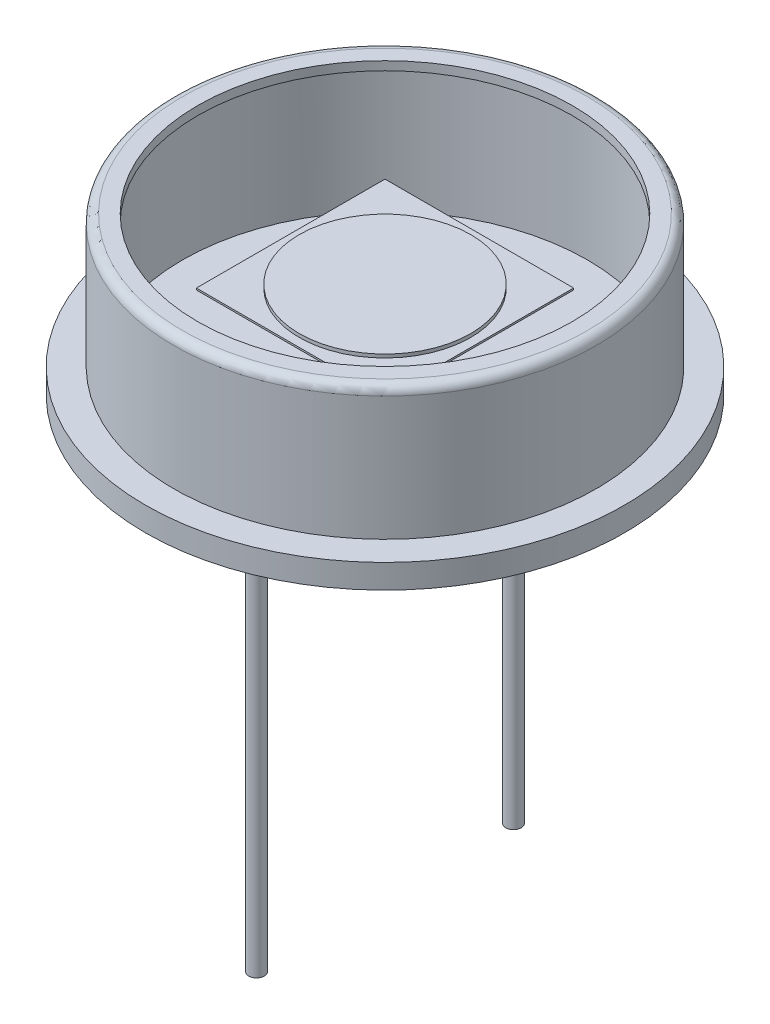
from build123d import *

# Parameters (mm, degrees)
SKETCH2_R           = 6.985
BOSS_EXTRUDE1_DEPTH = 0.446
BOSS_EXTRUDE2_START = -2.69
SKETCH3_W           = 5.5
SKETCH3_H           = 5.5
BOSS_EXTRUDE2_DEPTH = 0.05
SKETCH8_R           = 2.5
BOSS_EXTRUDE6_DEPTH = 0.1
SKETCH5_R           = 0.225
BOSS_EXTRUDE4_DEPTH = 12.7
SKETCH7_R           = 0.75
BOSS_EXTRUDE5_DEPTH = 0.4
SKETCH9_R           = 0.945778117
BOSS_EXTRUDE7_DEPTH = 0.01


with BuildPart() as part:
    # Sketch1 → Revolve-Thin2 (revolve)
    with BuildSketch(Plane.XY, mode=Mode.PRIVATE) as revolve_thin2_sk:
        with BuildLine():
            Line((6.985, 0), (6.985, 0.7))
            Line((6.985, 0.7), (6.16, 0.7))
            Line((6.16, 0.7), (6.16, 4.316))
            ThreePointArc((6.16, 4.316), (6.085605122, 4.495605122), (5.906, 4.57))
            Line((5.906, 4.57), (5.46, 4.57))
            Line((5.46, 4.57), (5.46, 4.316))
            Line((5.46, 4.316), (5.906, 4.316))
            Line((5.906, 4.316), (5.906, 0.446))
            Line((5.906, 0.446), (6.731, 0.446))
            Line((6.731, 0.446), (6.731, 0))
            Line((6.731, 0), (6.985, 0))
        make_face()
    revolve(revolve_thin2_sk.sketch.rotate(Axis((0, 0, 0), (0, 1, 0)), 90), axis=Axis((0, 0, 0), (0, 1, 0)))  # turned: the seam where the file's is

    # Sketch2 → Boss-Extrude1 (add)
    with BuildSketch(Plane.XZ):
        with Locations(Location((0, 0, 0), (0, 0, 270))):  # turned: the seam where the file's is
            Circle(SKETCH2_R)
    extrude(amount=-BOSS_EXTRUDE1_DEPTH)

    # Sketch5 → Boss-Extrude4 (add)
    with BuildSketch(Plane.XZ):
        with Locations(Location((0, -3.745, 0), (0, 0, 90))):  # turned: the seam where the file's is
            Circle(SKETCH5_R)
        with Locations(Location((0, 3.745, 0), (0, 0, 90))):  # turned: the seam where the file's is
            Circle(SKETCH5_R)
    extrude(amount=BOSS_EXTRUDE4_DEPTH)

    # Sketch7 → Boss-Extrude5 (add)
    with BuildSketch(Plane.XZ):
        with Locations(Location((0, 3.745, 0), (0, 0, 90))):  # turned: the seam where the file's is
            Circle(SKETCH7_R)
    extrude(amount=BOSS_EXTRUDE5_DEPTH)

    # Sketch9 → Boss-Extrude7 (add)
    with BuildSketch(Plane.XZ):
        with Locations(Location((-1.979317746, -4.717617413, 0), (0, 0, 90))):  # turned: the seam where the file's is
            Circle(SKETCH9_R)
    extrude(amount=BOSS_EXTRUDE7_DEPTH)


with BuildPart() as body_2:
    # Sketch3 → Boss-Extrude2 (new body)
    with BuildSketch(Plane.XZ.offset(BOSS_EXTRUDE2_START)):
        Rectangle(SKETCH3_W, SKETCH3_H)
    extrude(amount=BOSS_EXTRUDE2_DEPTH)

    # Sketch8 → Boss-Extrude6 (add)
    with BuildSketch(Plane(origin=(0, 2.69, 0), x_dir=(-1, 0, 0), z_dir=(0, 1, 0))):
        with Locations(Location((0, 0, 0), (0, 0, 270))):  # turned: the seam where the file's is
            Circle(SKETCH8_R)
    extrude(amount=BOSS_EXTRUDE6_DEPTH)


solid = Compound([part.part, body_2.part])
